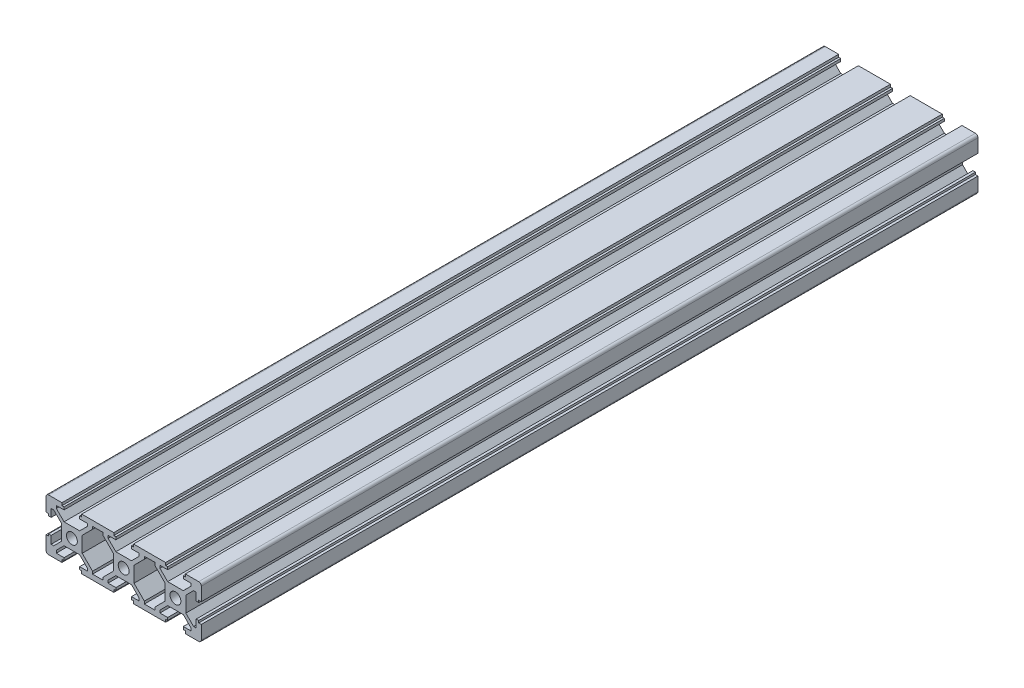
from build123d import *

# Parameters (mm, degrees)
SKETCH_1_R      = 2.103037388
EXTRUDE_1_DEPTH = 300


with BuildPart() as part:
    # 草图1 → 凸台-拉伸1 (new body)
    with BuildSketch(Plane.XY):
        with BuildLine():
            Line((-32.248557314, -0.229845073), (-32.248557314, -1.030984477))
            Line((-32.248557314, -1.030984477), (-33.250003689, -1.030984477))
            Line((-33.250003689, -1.030984477), (-33.250003689, -6.238394755))
            ThreePointArc((-33.250003689, -6.238394755), (-32.949991565, -6.938952391), (-32.24382973, -7.225524788))
            Line((-32.24382973, -7.225524788), (-27.078556151, -7.225524788))
            Line((-27.078556151, -7.225524788), (-27.078556151, -6.224078413))
            Line((-27.078556151, -6.224078413), (-26.277399051, -6.224078413))
            Line((-26.277399051, -6.224078413), (-26.277399051, -5.212715786))
            Line((-26.277399051, -5.212715786), (-29.27300496, -5.212715786))
            Line((-29.27300496, -5.212715786), (-29.27300496, -4.211495229))
            Line((-29.27300496, -4.211495229), (-26.279632969, -1.225390538))
            Line((-26.279632969, -1.225390538), (-20.24902045, -1.225390538))
            Line((-20.24902045, -1.225390538), (-17.255648459, -4.211495229))
            Line((-17.255648459, -4.211495229), (-17.255648459, -5.212715786))
            Line((-17.255648459, -5.212715786), (-20.251254368, -5.212715786))
            Line((-20.251254368, -5.212715786), (-20.251254368, -6.224078413))
            Line((-20.251254368, -6.224078413), (-19.450097268, -6.224078413))
            Line((-19.450097268, -6.224078413), (-19.450097268, -7.225524788))
            Line((-19.450097268, -7.225524788), (-7.064233131, -7.225524788))
            Line((-7.064233131, -7.225524788), (-7.064233131, -6.224078413))
            Line((-7.064233131, -6.224078413), (-6.263076031, -6.224078413))
            Line((-6.263076031, -6.224078413), (-6.263076031, -5.212715786))
            Line((-6.263076031, -5.212715786), (-9.25868194, -5.212715786))
            Line((-9.25868194, -5.212715786), (-9.25868194, -4.211495229))
            Line((-9.25868194, -4.211495229), (-6.265309949, -1.225390538))
            Line((-6.265309949, -1.225390538), (-0.234697429, -1.225390538))
            Line((-0.234697429, -1.225390538), (2.758674561, -4.211495229))
            Line((2.758674561, -4.211495229), (2.758674561, -5.212715786))
            Line((2.758674561, -5.212715786), (-0.236931348, -5.212715786))
            Line((-0.236931348, -5.212715786), (-0.236931348, -6.224078413))
            Line((-0.236931348, -6.224078413), (0.564225752, -6.224078413))
            Line((0.564225752, -6.224078413), (0.564225752, -7.225524788))
            Line((0.564225752, -7.225524788), (12.945482254, -7.225524788))
            Line((12.945482254, -7.225524788), (12.945482254, -6.219120287))
            Line((12.945482254, -6.219120287), (13.751246989, -6.219120287))
            Line((13.751246989, -6.219120287), (13.751246989, -5.212715786))
            Line((13.751246989, -5.212715786), (10.755641081, -5.212715786))
            Line((10.755641081, -5.212715786), (10.755641081, -4.211495229))
            Line((10.755641081, -4.211495229), (13.749013071, -1.225390538))
            Line((13.749013071, -1.225390538), (19.779625591, -1.225390538))
            Line((19.779625591, -1.225390538), (22.772997581, -4.211495229))
            Line((22.772997581, -4.211495229), (22.772997581, -5.212715786))
            Line((22.772997581, -5.212715786), (19.772784037, -5.212715786))
            Line((19.772784037, -5.212715786), (19.772784037, -6.219120287))
            Line((19.772784037, -6.219120287), (20.573941137, -6.219120287))
            Line((20.573941137, -6.219120287), (20.573941137, -7.225524788))
            Line((20.573941137, -7.225524788), (25.743822351, -7.225524788))
            ThreePointArc((25.743822351, -7.225524788), (26.449984187, -6.938952391), (26.749996311, -6.238394755))
            Line((26.749996311, -6.238394755), (26.749996311, -1.030984477))
            Line((26.749996311, -1.030984477), (25.748549936, -1.030984477))
            Line((25.748549936, -1.030984477), (25.748549936, -0.229827377))
            Line((25.748549936, -0.229827377), (24.761302481, -0.229827377))
            Line((24.761302481, -0.229827377), (24.761302481, -3.234203038))
            Line((24.761302481, -3.234203038), (23.759856106, -3.234203038))
            Line((23.759856106, -3.234203038), (20.770104831, -0.237175589))
            Line((20.770104831, -0.237175589), (20.770104831, 5.786126014))
            Line((20.770104831, 5.786126014), (23.759856106, 8.783153462))
            Line((23.759856106, 8.783153462), (24.761302481, 8.783153462))
            Line((24.761302481, 8.783153462), (24.761302481, 5.778777801))
            Line((24.761302481, 5.778777801), (25.748549936, 5.778777801))
            Line((25.748549936, 5.778777801), (25.748549936, 6.579934901))
            Line((25.748549936, 6.579934901), (26.749996311, 6.579934901))
            Line((26.749996311, 6.579934901), (26.749996311, 11.768212512))
            ThreePointArc((26.749996311, 11.768212512), (26.456722319, 12.481138347), (25.743822351, 12.774475212))
            Line((25.743822351, 12.774475212), (20.573941137, 12.774475212))
            Line((20.573941137, 12.774475212), (20.573941137, 11.768070711))
            Line((20.573941137, 11.768070711), (19.772784037, 11.768070711))
            Line((19.772784037, 11.768070711), (19.772784037, 10.761666211))
            Line((19.772784037, 10.761666211), (22.772997581, 10.761666211))
            Line((22.772997581, 10.761666211), (22.772997581, 9.760445653))
            Line((22.772997581, 9.760445653), (19.779625591, 6.774340962))
            Line((19.779625591, 6.774340962), (13.749013071, 6.774340962))
            Line((13.749013071, 6.774340962), (10.755641081, 9.760445653))
            Line((10.755641081, 9.760445653), (10.755641081, 10.761666211))
            Line((10.755641081, 10.761666211), (13.746639354, 10.761666211))
            Line((13.746639354, 10.761666211), (13.746639354, 11.768070711))
            Line((13.746639354, 11.768070711), (12.945482254, 11.768070711))
            Line((12.945482254, 11.768070711), (12.945482254, 12.774475212))
            Line((12.945482254, 12.774475212), (0.564225752, 12.774475212))
            Line((0.564225752, 12.774475212), (0.564225752, 11.773028837))
            Line((0.564225752, 11.773028837), (-0.236931348, 11.773028837))
            Line((-0.236931348, 11.773028837), (-0.236931348, 10.761666211))
            Line((-0.236931348, 10.761666211), (2.758674561, 10.761666211))
            Line((2.758674561, 10.761666211), (2.758674561, 9.760445653))
            Line((2.758674561, 9.760445653), (-0.234697429, 6.774340962))
            Line((-0.234697429, 6.774340962), (-6.265309949, 6.774340962))
            Line((-6.265309949, 6.774340962), (-9.25868194, 9.760445653))
            Line((-9.25868194, 9.760445653), (-9.25868194, 10.761666211))
            Line((-9.25868194, 10.761666211), (-6.263076031, 10.761666211))
            Line((-6.263076031, 10.761666211), (-6.263076031, 11.773028837))
            Line((-6.263076031, 11.773028837), (-7.064233131, 11.773028837))
            Line((-7.064233131, 11.773028837), (-7.064233131, 12.774475212))
            Line((-7.064233131, 12.774475212), (-19.450097268, 12.774475212))
            Line((-19.450097268, 12.774475212), (-19.450097268, 11.773028837))
            Line((-19.450097268, 11.773028837), (-20.251254368, 11.773028837))
            Line((-20.251254368, 11.773028837), (-20.251254368, 10.761666211))
            Line((-20.251254368, 10.761666211), (-17.255648459, 10.761666211))
            Line((-17.255648459, 10.761666211), (-17.255648459, 9.760445653))
            Line((-17.255648459, 9.760445653), (-20.24902045, 6.774340962))
            Line((-20.24902045, 6.774340962), (-26.279632969, 6.774340962))
            Line((-26.279632969, 6.774340962), (-29.27300496, 9.760445653))
            Line((-29.27300496, 9.760445653), (-29.27300496, 10.761666211))
            Line((-29.27300496, 10.761666211), (-26.277399051, 10.761666211))
            Line((-26.277399051, 10.761666211), (-26.277399051, 11.773028837))
            Line((-26.277399051, 11.773028837), (-27.078556151, 11.773028837))
            Line((-27.078556151, 11.773028837), (-27.078556151, 12.774475212))
            Line((-27.078556151, 12.774475212), (-32.24382973, 12.774475212))
            ThreePointArc((-32.24382973, 12.774475212), (-32.956729698, 12.481138347), (-33.250003689, 11.768212512))
            Line((-33.250003689, 11.768212512), (-33.250003689, 6.560802234))
            Line((-33.250003689, 6.560802234), (-32.248557314, 6.560802234))
            Line((-32.248557314, 6.560802234), (-32.248557314, 5.759645134))
            Line((-32.248557314, 5.759645134), (-31.261309859, 5.759645134))
            Line((-31.261309859, 5.759645134), (-31.261309859, 8.764020795))
            Line((-31.261309859, 8.764020795), (-30.259863484, 8.764020795))
            Line((-30.259863484, 8.764020795), (-27.27011221, 5.766993347))
            Line((-27.27011221, 5.766993347), (-27.27011221, -0.237175589))
            Line((-27.27011221, -0.237175589), (-30.259863484, -3.234203038))
            Line((-30.259863484, -3.234203038), (-31.261309859, -3.234203038))
            Line((-31.261309859, -3.234203038), (-31.261309859, -0.229845073))
            Line((-31.261309859, -0.229845073), (-32.248557314, -0.229845073))
        make_face()
        with Locations((-3.250003689, 2.774475212)):
            Circle(SKETCH_1_R, mode=Mode.SUBTRACT)
        with Locations((-23.250003689, 2.774475212)):
            Circle(SKETCH_1_R, mode=Mode.SUBTRACT)
        with Locations((16.749996311, 2.774475212)):
            Circle(SKETCH_1_R, mode=Mode.SUBTRACT)
        Polygon((-19.258541209, 5.786126014), (-19.258541209, -0.237175589), (-15.26734356, -4.238086639), (-15.26734356, -5.22228212), (-11.246986839, -5.22228212), (-11.246986839, -4.238086639), (-7.25578919, -0.237175589), (-7.25578919, 2.774475212), (-7.25578919, 5.786126014), (-11.246986839, 9.787037063), (-11.246986839, 10.771232544), (-15.26734356, 10.771232544), (-15.26734356, 9.787037063), align=None, mode=Mode.SUBTRACT)
        Polygon((4.74697946, -5.22228212), (8.767336181, -5.22228212), (8.767336181, -4.238086639), (12.758533831, -0.237175589), (12.758533831, 2.774475212), (12.758533831, 5.786126014), (8.767336181, 9.787037063), (8.767336181, 10.771232544), (4.74697946, 10.771232544), (4.74697946, 9.787037063), (0.755781811, 5.786126014), (0.755781811, 2.774475212), (0.755781811, -0.237175589), (4.74697946, -4.238086639), align=None, mode=Mode.SUBTRACT)
    extrude(amount=EXTRUDE_1_DEPTH)


solid = part.part
